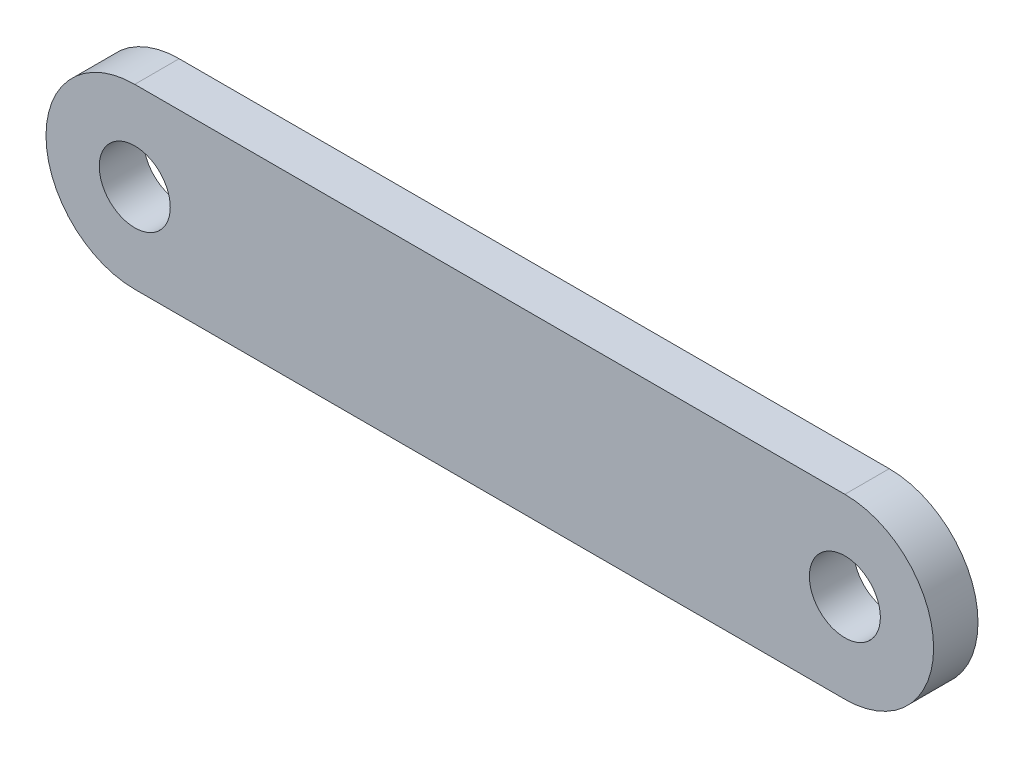
from build123d import *

# Parameters (mm, degrees)
SKETCH1_R           = 0.8
BOSS_EXTRUDE1_DEPTH = 1


with BuildPart() as part:
    # Sketch1 → Boss-Extrude1 (new body)
    with BuildSketch(Plane.XY):
        with BuildLine():
            Line((16, -2), (0, -2))
            ThreePointArc((0, -2), (-2, 0), (0, 2))
            Line((0, 2), (16, 2))
            ThreePointArc((16, 2), (18, 0), (16, -2))
        make_face()
        Circle(SKETCH1_R, mode=Mode.SUBTRACT)
        with Locations((16, 0)):
            Circle(SKETCH1_R, mode=Mode.SUBTRACT)
    extrude(amount=BOSS_EXTRUDE1_DEPTH)


solid = part.part
